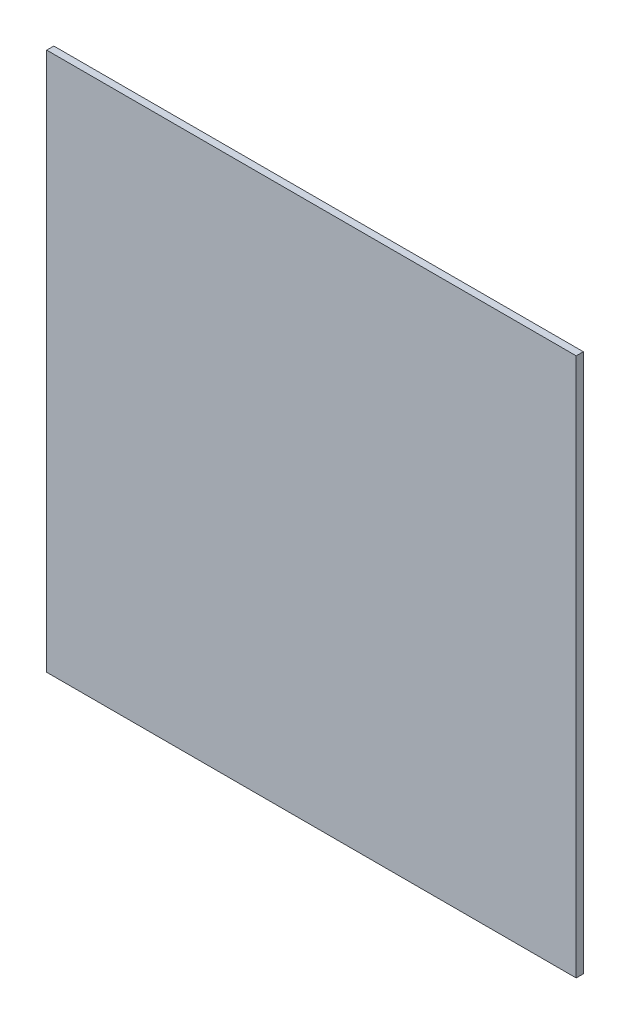
from build123d import *

# Parameters (mm, degrees)
SKETCH1_W           = 472.69
SKETCH1_H           = 481.00261168
BOSS_EXTRUDE1_DEPTH = 6.35


with BuildPart() as part:
    # Sketch1 → Boss-Extrude1 (new body)
    with BuildSketch(Plane.XY):
        with Locations((236.345, -240.50130584)):
            Rectangle(SKETCH1_W, SKETCH1_H)
    extrude(amount=BOSS_EXTRUDE1_DEPTH)


solid = part.part
